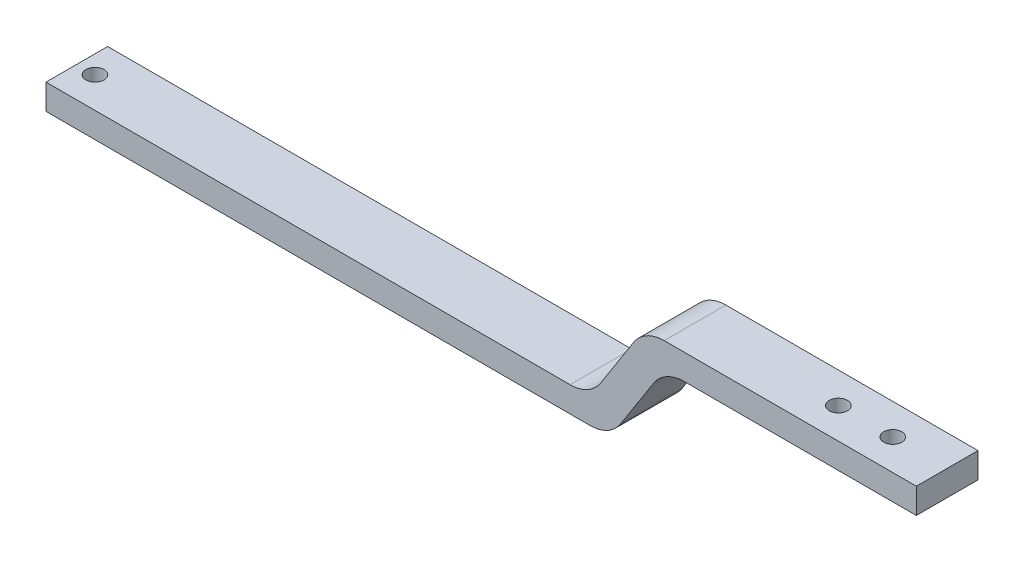
from build123d import *

# Parameters (mm, degrees)
EXTRUDE1_DEPTH = 17
FILLET1_R      = 10
SKETCH2_R      = 2.5
EXTRUDE2_DEPTH = 17
SKETCH3_R      = 2.5
EXTRUDE3_DEPTH = 17


with BuildPart() as part:
    # Sketch1 → Extrude1 (new body)
    with BuildSketch(Plane.XY):
        Polygon((-145.737121951, 14.824159554), (4.262878049, 14.824159554), (19.262878049, 38.324159554), (94.262878049, 38.324159554), (94.262878049, 31.324159554), (24.769095529, 31.324159554), (9.769095529, 7.824159554), (-145.737121951, 7.824159554), align=None)
    extrude(amount=EXTRUDE1_DEPTH)

    # Fillet1
    fillet1_edges = [part.edges().sort_by_distance(p)[0] for p in [
        (4.262878049, 14.824159554, 8.5),
        (19.262878049, 38.324159554, 8.5),
        (24.769095529, 31.324159554, 8.5),
        (9.769095529, 7.824159554, 8.5),
    ]]
    fillet(fillet1_edges, radius=FILLET1_R)

    # Sketch2 → Extrude2 (cut)
    with BuildSketch(Plane(origin=(0, 38.324159554, 0), x_dir=(1, 0, 0), z_dir=(0, 1, 0))):
        with Locations((79.262878049, -8.5)):
            Circle(SKETCH2_R)
        with Locations((64.262878049, -8.5)):
            Circle(SKETCH2_R)
    extrude(amount=-EXTRUDE2_DEPTH, mode=Mode.SUBTRACT)

    # Sketch3 → Extrude3 (cut)
    with BuildSketch(Plane.XZ.offset(-7.824159554)):
        with Locations((-140.737121951, 8.5)):
            Circle(SKETCH3_R)
    extrude(amount=-EXTRUDE3_DEPTH, mode=Mode.SUBTRACT)


solid = part.part
